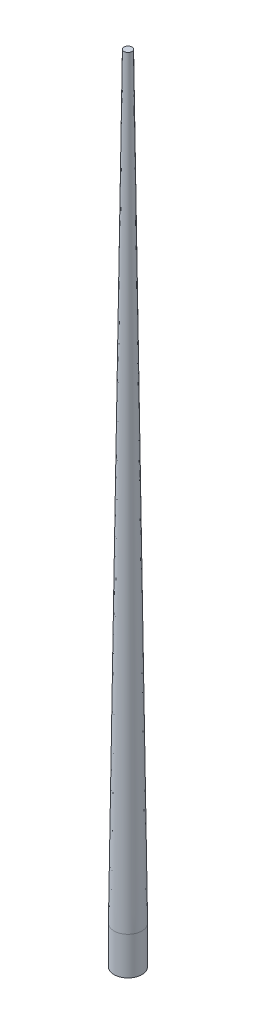
from build123d import *

# Parameters (mm, degrees)
SKETCH2_R                     = 11
BOSS_EXTRUDE1_DEPTH           = 600
BOSS_EXTRUDE1_TAPER           = 0.75
BOSS_EXTRUDE1_OTHER_WAY_DEPTH = 30


with BuildPart() as part:
    # Sketch2 → Boss-Extrude1 (new body)
    with BuildSketch(Plane(origin=(0, 0, 0), x_dir=(1, 0, 0), z_dir=(0, 1, 0))):
        Circle(SKETCH2_R)
    extrude(amount=BOSS_EXTRUDE1_DEPTH, taper=BOSS_EXTRUDE1_TAPER)

    # Sketch2 → Boss-Extrude1 other way (add)
    with BuildSketch(Plane(origin=(0, 0, 0), x_dir=(1, 0, 0), z_dir=(0, 1, 0))):
        Circle(SKETCH2_R)
    extrude(amount=-BOSS_EXTRUDE1_OTHER_WAY_DEPTH)


solid = part.part
